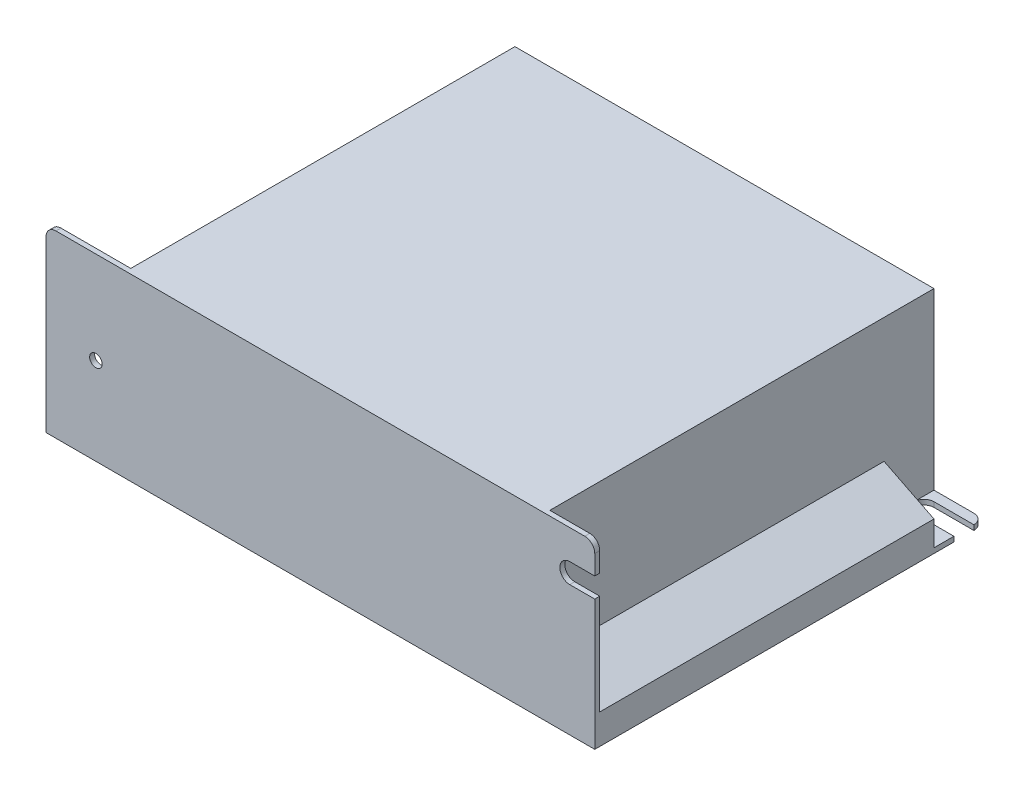
from build123d import *

# Parameters (mm, degrees)
SKETCH1_W             = 110
SKETCH1_H             = 78
BOSS_EXTRUDE1_DEPTH   = 36
M3_TAPPED_HOLE2_D     = 2.5
M3_TAPPED_HOLE2_DEPTH = 5
M3_TAPPED_HOLE2_TIP   = 0.751075774
SKETCH8_W             = 16
SKETCH8_H             = 77
CUT_EXTRUDE2_DEPTH    = 35
F_3_0MM_DOWEL_HOLE1_D = 3
SKETCH12_W            = 10
SKETCH12_H            = 67
CUT_EXTRUDE4_DEPTH    = 25
SKETCH13_W            = 10
SKETCH13_H            = 10
CUT_EXTRUDE5_DEPTH    = 35
CUT_EXTRUDE7_DEPTH    = 67
CUT_EXTRUDE8_DEPTH    = 2
M3_TAPPED_HOLE3_D     = 2.5
FILLET1_R             = 2
CUT_EXTRUDE9_DEPTH    = 37


with BuildPart() as part:
    # Sketch1 → Boss-Extrude1 (new body)
    with BuildSketch(Plane(origin=(0, 0, 0), x_dir=(1, 0, 0), z_dir=(0, 1, 0))):
        with Locations((55, 39)):
            Rectangle(SKETCH1_W, SKETCH1_H)
    extrude(amount=BOSS_EXTRUDE1_DEPTH)

    # M3 Tapped Hole2
    with Locations(Plane(origin=(0, 0, 0), x_dir=(-1, 0, 0), z_dir=(0, -1, 0))):
        with Locations((-67.5, 25), (-67.5, 52.5), (-31.5, 52.5)):
            Hole(M3_TAPPED_HOLE2_D / 2, depth=M3_TAPPED_HOLE2_DEPTH)
            with Locations((0, 0, -(M3_TAPPED_HOLE2_DEPTH + M3_TAPPED_HOLE2_TIP / 2))):  # 118° drill point
                Cone(0, M3_TAPPED_HOLE2_D / 2, M3_TAPPED_HOLE2_TIP, mode=Mode.SUBTRACT)

    # Sketch8 → Cut-Extrude2 (cut)
    with BuildSketch(Plane(origin=(0, 36, 0), x_dir=(1, 0, 0), z_dir=(0, 1, 0))):
        with Locations((8, 39.5)):
            Rectangle(SKETCH8_W, SKETCH8_H)
    extrude(amount=-CUT_EXTRUDE2_DEPTH, mode=Mode.SUBTRACT)

    # Ø3.0mm Dowel Hole1 (through all)
    with Locations(Plane(origin=(0, 0, 0), x_dir=(-1, 0, 0), z_dir=(0, -1, 0))):
        with Locations((-5, 4)):
            Hole(F_3_0MM_DOWEL_HOLE1_D / 2)

    # Sketch12 → Cut-Extrude4 (cut)
    with BuildSketch(Plane(origin=(0, 36, 0), x_dir=(1, 0, 0), z_dir=(0, 1, 0))):
        with Locations((105, 34.5)):
            Rectangle(SKETCH12_W, SKETCH12_H)
    extrude(amount=-CUT_EXTRUDE4_DEPTH, mode=Mode.SUBTRACT)

    # Sketch13 → Cut-Extrude5 (cut)
    with BuildSketch(Plane(origin=(0, 36, 0), x_dir=(1, 0, 0), z_dir=(0, 1, 0))):
        with Locations((105, 73)):
            Rectangle(SKETCH13_W, SKETCH13_H)
    extrude(amount=-CUT_EXTRUDE5_DEPTH, mode=Mode.SUBTRACT)

    # Sketch15 → Cut-Extrude7 (cut)
    with BuildSketch(Plane(origin=(0, 0, -68), x_dir=(-1, 0, 0), z_dir=(0, 0, -1))):
        Polygon((-110, 6), (-100, 11), (-110, 11), align=None)
    extrude(amount=-CUT_EXTRUDE7_DEPTH, mode=Mode.SUBTRACT)

    # Sketch16 → Cut-Extrude8 (cut, through all)
    with BuildSketch(Plane(origin=(0, 0, -1), x_dir=(-1, 0, 0), z_dir=(0, 0, -1))):
        with BuildLine():
            Line((-115, 30.09689573), (-105, 30.09689573))
            ThreePointArc((-105, 30.09689573), (-103, 28.09689573), (-105, 26.09689573))
            Line((-105, 26.09689573), (-115, 26.09689573))
            ThreePointArc((-115, 26.09689573), (-117, 28.09689573), (-115, 30.09689573))
        make_face()
    extrude(amount=-CUT_EXTRUDE8_DEPTH, mode=Mode.SUBTRACT)

    # M3 Tapped Hole3 (through all)
    with Locations(Plane.XY):
        with Locations((10, 17.5)):
            Hole(M3_TAPPED_HOLE3_D / 2)

    # Fillet1
    fillet1_edges = [part.edges().sort_by_distance(p)[0] for p in [
        (110, 36, -0.5),
        (0, 36, -0.5),
        (0, 0.5, -78),
        (110, 0.5, -78),
    ]]
    fillet(fillet1_edges, radius=FILLET1_R)

    # Sketch20 → Cut-Extrude9 (cut, through all)
    with BuildSketch(Plane(origin=(0, 0, 0), x_dir=(-1, 0, 0), z_dir=(0, -1, 0))):
        with BuildLine():
            Line((-102, 72), (-113.136440261, 72))
            ThreePointArc((-113.136440261, 72), (-115.136440261, 74), (-113.136440261, 76))
            Line((-113.136440261, 76), (-102, 76))
            ThreePointArc((-102, 76), (-100, 74), (-102, 72))
        make_face()
    extrude(amount=-CUT_EXTRUDE9_DEPTH, mode=Mode.SUBTRACT)


solid = part.part
